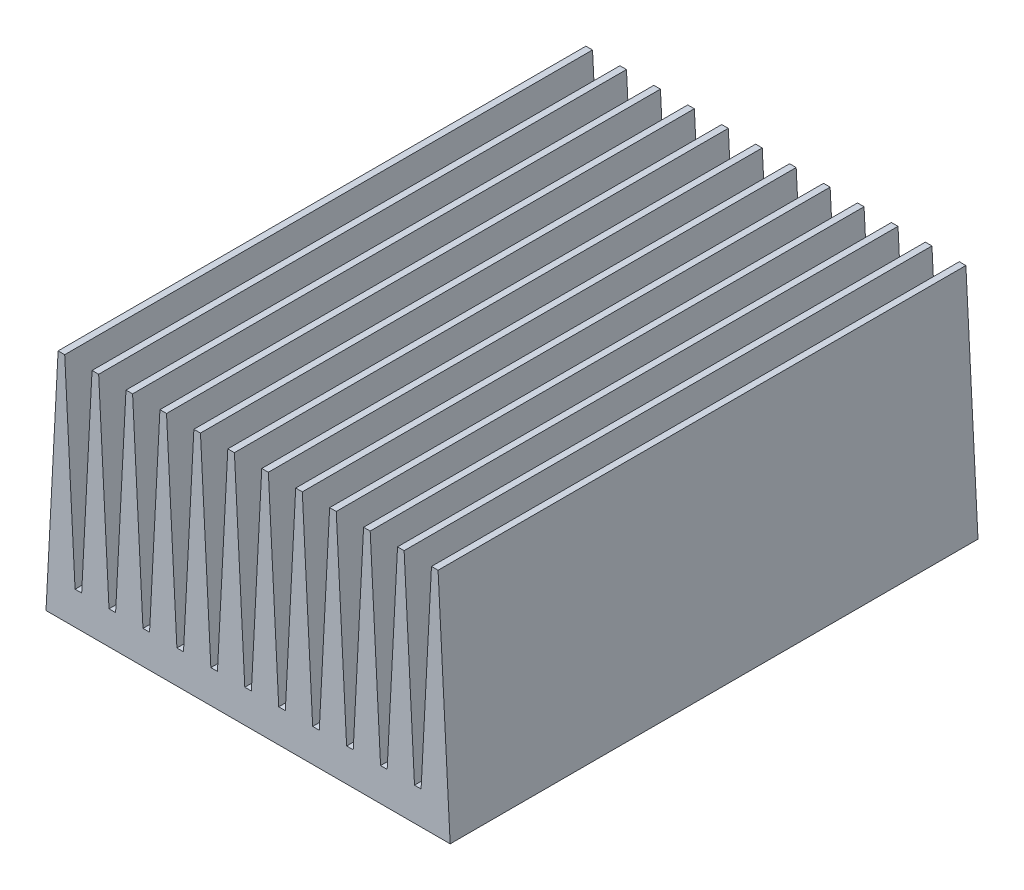
from build123d import *

# Parameters (mm, degrees)
BOSS_EXTRUDE1_DEPTH = 80


with BuildPart() as part:
    # Sketch1 → Boss-Extrude1 (new body)
    with BuildSketch(Plane.XY):
        Polygon((0, 0), (61.257678877, 0), (59.423406602, 35), (58.423406602, 35), (56.851173223, 5), (55.851173223, 5), (54.278939845, 35), (53.278939845, 35), (51.706706466, 5), (50.706706466, 5), (49.134473088, 35), (48.134473088, 35), (46.562239709, 5), (45.562239709, 5), (43.990006331, 35), (42.990006331, 35), (41.417772952, 5), (40.417772952, 5), (38.845539574, 35), (37.845539574, 35), (36.273306195, 5), (35.273306195, 5), (33.701072817, 35), (32.701072817, 35), (31.128839438, 5), (30.128839438, 5), (28.55660606, 35), (27.55660606, 35), (25.984372681, 5), (24.984372681, 5), (23.412139303, 35), (22.412139303, 35), (20.839905924, 5), (19.839905924, 5), (18.267672546, 35), (17.267672546, 35), (15.695439167, 5), (14.695439167, 5), (13.123205789, 35), (12.123205789, 35), (10.55097241, 5), (9.55097241, 5), (7.978739032, 35), (6.978739032, 35), (5.406505653, 5), (4.406505653, 5), (2.834272275, 35), (1.834272275, 35), (0.262038896, 5), align=None)
    extrude(amount=BOSS_EXTRUDE1_DEPTH)


solid = part.part
